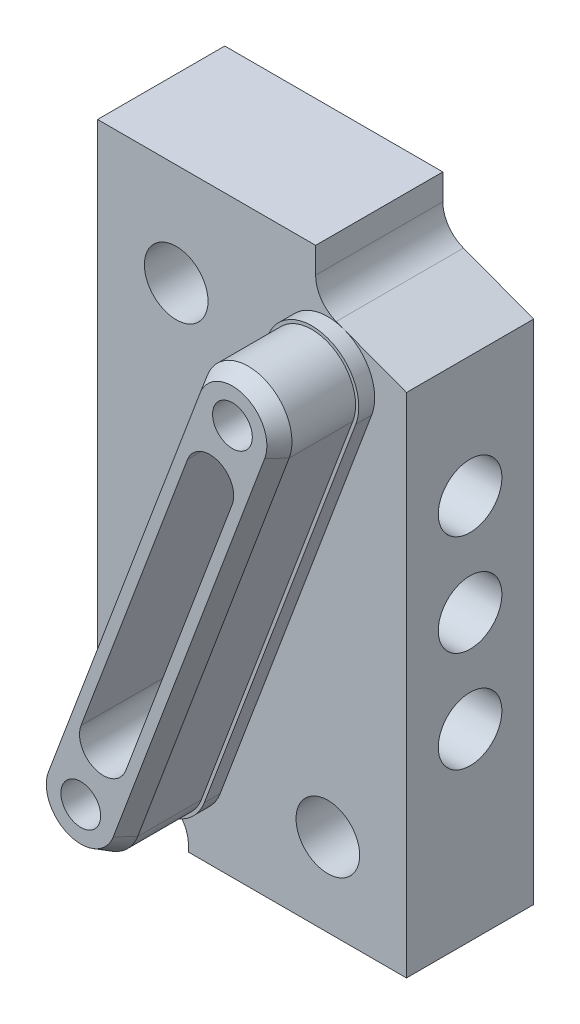
from build123d import *
from OCP.BRepFilletAPI import BRepFilletAPI_MakeChamfer

# Parameters (mm, degrees)
BOSS_EXTRUDE1_DEPTH      = 6
SKETCH2_W                = 15.427107808
SKETCH2_H                = 31.27334873
BOSS_EXTRUDE2_DEPTH      = 8
CUT_EXTRUDE1_DEPTH       = 23.360780376
CUT_EXTRUDE2_DEPTH       = 5
CHAMFER1_SIZE            = 1
CHAMFER1_SIZE2           = 0.577350269
CUT_EXTRUDE4_DEPTH       = 20.183443357
SKETCH17_W               = 2
SKETCH17_H               = 3.5
BOSS_EXTRUDE3_DEPTH      = 8
CIRPATTERN1_COUNT        = 2
FILLET3_R                = 2
SKETCH20_W               = 13.713553904
SKETCH20_H               = 1.226825257
CUT_EXTRUDE5_DEPTH       = 23.90339353
F_4_0_4_DIAMETER_HOLE3_D = 4
M3X0_5_TAPPED_HOLE1_D    = 2.5
F_4_0_4_DIAMETER_HOLE5_D = 4


with BuildPart() as part:
    # Sketch1 → Boss-Extrude1 (new body)
    with BuildSketch(Plane.XY):
        with BuildLine():
            Line((2.001816135, 13.723643263), (-7.525291673, -11.649705468))
            ThreePointArc((-7.525291673, -11.649705468), (-5.800522802, -15.448412135), (-2.001816135, -13.723643263))
            Line((-2.001816135, -13.723643263), (7.525291673, 11.649705468))
            ThreePointArc((7.525291673, 11.649705468), (5.800522802, 15.448412135), (2.001816135, 13.723643263))
        make_face()
    extrude(amount=BOSS_EXTRUDE1_DEPTH)

    # Sketch2 → Boss-Extrude2 (add)
    with BuildSketch(Plane(origin=(0, 0, 0), x_dir=(-1, 0, 0), z_dir=(0, 0, -1))):
        Rectangle(SKETCH2_W, SKETCH2_H)
    extrude(amount=BOSS_EXTRUDE2_DEPTH)

    # Sketch3 → Cut-Extrude1 (cut, through all)
    with BuildSketch(Plane.XY.offset(6)):
        with BuildLine():
            Line((1.943905795, 9.444408677), (-4.752452679, -8.389864035))
            ThreePointArc((-4.752452679, -8.389864035), (-3.875451558, -10.321409798), (-1.943905795, -9.444408677))
            Line((-1.943905795, -9.444408677), (4.752452679, 8.389864035))
            ThreePointArc((4.752452679, 8.389864035), (3.875451558, 10.321409798), (1.943905795, 9.444408677))
        make_face()
    extrude(amount=-CUT_EXTRUDE1_DEPTH, mode=Mode.SUBTRACT)

    # Sketch4 → Cut-Extrude2 (cut)
    with BuildSketch(Plane.XY.offset(6)):
        with BuildLine():
            Line((2.001816135, 13.723643263), (-7.525291673, -11.649705468))
            ThreePointArc((-7.525291673, -11.649705468), (-5.800522802, -15.448412135), (-2.001816135, -13.723643263))
            Line((-2.001816135, -13.723643263), (7.525291673, 11.649705468))
            ThreePointArc((7.525291673, 11.649705468), (5.800522802, 15.448412135), (2.001816135, 13.723643263))
        make_face()
        with BuildLine():
            Line((2.189052594, 13.653340287), (-7.338055214, -11.720008444))
            ThreePointArc((-7.338055214, -11.720008444), (-5.730219825, -15.261175676), (-2.189052594, -13.653340287))
            Line((-2.189052594, -13.653340287), (7.338055214, 11.720008444))
            ThreePointArc((7.338055214, 11.720008444), (5.730219825, 15.261175676), (2.189052594, 13.653340287))
        make_face(mode=Mode.SUBTRACT)
    extrude(amount=-CUT_EXTRUDE2_DEPTH, mode=Mode.SUBTRACT)

    # Chamfer1: one chamfer whose edges measure the first distance from different faces: ONE call of the kernel's chamfer builder (chamfer() names one face for all edges)
    chamfer1_edges_1 = [part.edges().sort_by_distance(p)[0] for p in [
        (2.57450131, -0.966665922, 6),
    ]]
    chamfer1_side_1 = [part.faces().sort_by_distance(p)[0] for p in [
        (2.57450131, -0.966665922, 3.5),
    ]]
    chamfer1_edges_2 = [part.edges().sort_by_distance(p)[0] for p in [
        (5.730219825, 15.261175676, 6),
    ]]
    chamfer1_side_2 = [part.faces().sort_by_distance(p)[0] for p in [
        (5.730219825, 15.261175676, 3.5),
    ]]
    chamfer1_edges_3 = [part.edges().sort_by_distance(p)[0] for p in [
        (-2.57450131, 0.966665922, 6),
    ]]
    chamfer1_side_3 = [part.faces().sort_by_distance(p)[0] for p in [
        (-2.57450131, 0.966665922, 3.5),
    ]]
    chamfer1_edges_4 = [part.edges().sort_by_distance(p)[0] for p in [
        (-5.730219825, -15.261175676, 6),
    ]]
    chamfer1_side_4 = [part.faces().sort_by_distance(p)[0] for p in [
        (-5.730219825, -15.261175676, 3.5),
    ]]
    chamfer1 = BRepFilletAPI_MakeChamfer(part.part.solid().wrapped)
    for e in chamfer1_edges_1:
        chamfer1.Add(CHAMFER1_SIZE, CHAMFER1_SIZE2, e.wrapped, chamfer1_side_1[0].wrapped)  # the first distance lies on this face
    for e in chamfer1_edges_2:
        chamfer1.Add(CHAMFER1_SIZE, CHAMFER1_SIZE2, e.wrapped, chamfer1_side_2[0].wrapped)  # the first distance lies on this face
    for e in chamfer1_edges_3:
        chamfer1.Add(CHAMFER1_SIZE, CHAMFER1_SIZE2, e.wrapped, chamfer1_side_3[0].wrapped)  # the first distance lies on this face
    for e in chamfer1_edges_4:
        chamfer1.Add(CHAMFER1_SIZE, CHAMFER1_SIZE2, e.wrapped, chamfer1_side_4[0].wrapped)  # the first distance lies on this face
    add(Compound.cast(chamfer1.Shape()), mode=Mode.REPLACE)

    # Sketch11 → Cut-Extrude4 (cut, through all)
    with BuildSketch(Plane.XY):
        with BuildLine():
            Line((4.763553904, 15.636674365), (7.713553904, 15.636674365))
            Line((7.713553904, 15.636674365), (7.713553904, 12.686674365))
            ThreePointArc((7.713553904, 12.686674365), (6.849518908, 14.77263937), (4.763553904, 15.636674365))
        make_face()
        with BuildLine():
            Line((-7.713553904, -12.686674365), (-7.713553904, -15.636674365))
            Line((-7.713553904, -15.636674365), (-4.763553904, -15.636674365))
            ThreePointArc((-4.763553904, -15.636674365), (-6.849518908, -14.77263937), (-7.713553904, -12.686674365))
        make_face()
    extrude(amount=-CUT_EXTRUDE4_DEPTH, mode=Mode.SUBTRACT)

    # Sketch17 → Boss-Extrude3 (add, through all)
    with BuildSketch(Plane.XY):
        with BuildLine():
            Line((7.713553904, 12.686674365), (7.713553904, -15.636674365))
            Line((7.713553904, -15.636674365), (9.713553904, -15.636674365))
            Line((9.713553904, -15.636674365), (9.713553904, 13.979159118))
            Line((9.713553904, 13.979159118), (5.800522802, 15.448412135))
            ThreePointArc((5.800522802, 15.448412135), (7.188585682, 14.366472233), (7.713553904, 12.686674365))
        make_face()
        with BuildLine():
            ThreePointArc((4.763553904, 15.636674365), (5.290513855, 15.589227243), (5.800522802, 15.448412135))
            Line((5.800522802, 15.448412135), (4, 16.12446696))
            Line((4, 16.12446696), (4, 19.136674365))
            Line((4, 19.136674365), (-7.713553904, 19.136674365))
            Line((-7.713553904, 19.136674365), (-7.713553904, 15.636674365))
            Line((-7.713553904, 15.636674365), (4.763553904, 15.636674365))
        make_face()
        with Locations((-8.713553904, 17.386674365)):
            Rectangle(SKETCH17_W, SKETCH17_H)
    boss_extrude3 = extrude(amount=-BOSS_EXTRUDE3_DEPTH)

    # CirPattern1: Boss-Extrude3 ×2 about axis
    cirpattern1_axis = Axis((0, 0, 0), (0, 0, 1))
    for i in range(1, CIRPATTERN1_COUNT):
        add(boss_extrude3.rotate(cirpattern1_axis, i * 360 / CIRPATTERN1_COUNT))

    # Fillet3
    fillet3_edges = [part.edges().sort_by_distance(p)[0] for p in [
        (4, 16.12446696, -4),
        (-4, -16.12446696, -4),
    ]]
    fillet(fillet3_edges, radius=FILLET3_R)

    # Sketch20 → Cut-Extrude5 (cut, through all)
    with BuildSketch(Plane.XY):
        with Locations((2.856776952, -18.523261737)):
            Rectangle(SKETCH20_W, SKETCH20_H)
    extrude(amount=-CUT_EXTRUDE5_DEPTH, mode=Mode.SUBTRACT)

    # 4.0 _4_ Diameter Hole3 (through all)
    with Locations(Plane(origin=(-9.713553904, 2.428457005, -0.24781288), x_dir=(0, 0, 1), z_dir=(-1, 0, 0))):
        with Locations((-3.75218712, 3.921542995), (-3.75218712, -8.778457005), (-3.75218712, -2.428457005)):
            Hole(F_4_0_4_DIAMETER_HOLE3_D / 2)

    # M3x0.5 Tapped Hole1 (through all)
    with Locations(Plane.XY.offset(6)):
        with Locations((-4.768557373, -12.7), (4.768557373, 12.7)):
            Hole(M3X0_5_TAPPED_HOLE1_D / 2)

    # 4.0 _4_ Diameter Hole5 (through all)
    with Locations(Plane.XY):
        with Locations((-4.768557373, 12.7), (4.768557373, -12.7)):
            Hole(F_4_0_4_DIAMETER_HOLE5_D / 2)


solid = part.part
